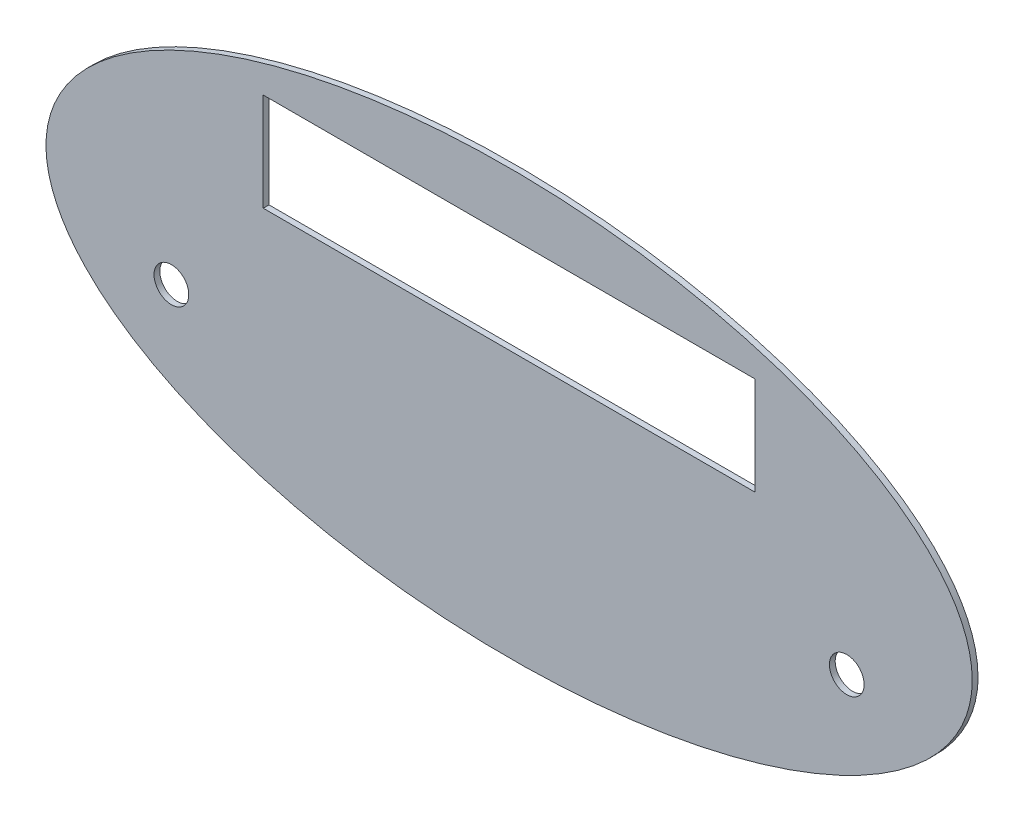
from build123d import *

# Parameters (mm, degrees)
SKETCH1_RX          = 240
SKETCH1_RY          = 110
BOSS_EXTRUDE1_DEPTH = 3
SKETCH10_W          = 254.8
SKETCH10_H          = 50.8
CUT_EXTRUDE5_DEPTH  = 4
SKETCH12_R          = 9
CUT_EXTRUDE8_DEPTH  = 4


with BuildPart() as part:
    # Sketch1 → Boss-Extrude1 (new body)
    with BuildSketch(Plane.XY):
        with Locations((0, 0)):
            Ellipse(SKETCH1_RX, SKETCH1_RY)
    extrude(amount=-BOSS_EXTRUDE1_DEPTH)

    # Sketch10 → Cut-Extrude5 (cut, through all)
    with BuildSketch(Plane.XY):
        with Locations((0, 53.5)):
            Rectangle(SKETCH10_W, SKETCH10_H)
    extrude(amount=-CUT_EXTRUDE5_DEPTH, mode=Mode.SUBTRACT)

    # Sketch12 → Cut-Extrude8 (cut, through all)
    with BuildSketch(Plane.XY):
        with Locations((175, -30)):
            Circle(SKETCH12_R)
        with Locations((-175, -30)):
            Circle(SKETCH12_R)
    extrude(amount=-CUT_EXTRUDE8_DEPTH, mode=Mode.SUBTRACT)


solid = part.part
